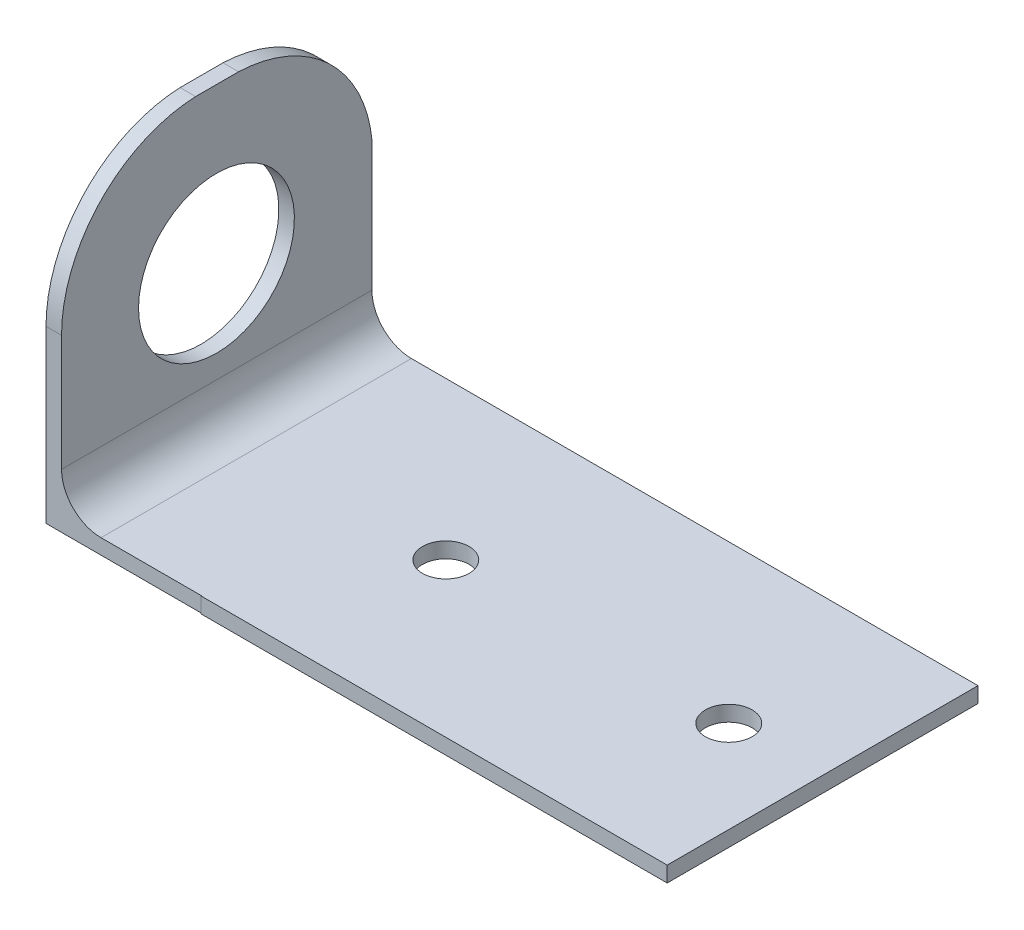
from build123d import *

# Parameters (mm, degrees)
EXTRUDE1_DEPTH     = 20
FILLET1_R          = 2.54
SKETCH8_R          = 5.014710823
CUT_EXTRUDE2_DEPTH = 10
CUT_EXTRUDE5_DEPTH = 10
CUT_EXTRUDE6_DEPTH = 10
CUT_EXTRUDE7_DEPTH = 30


with BuildPart() as part:
    # Sketch1 → Extrude1 (new body)
    with BuildSketch(Plane.XY):
        Polygon((1, 20), (1, 1), (40, 1), (40, 0), (0, 0), (0, 20), align=None)
    extrude(amount=EXTRUDE1_DEPTH)

    # Fillet1
    fillet1_edges = [part.edges().sort_by_distance(p)[0] for p in [
        (1, 1, 10),
    ]]
    fillet(fillet1_edges, radius=FILLET1_R)

    # Sketch8 → Cut-Extrude2 (cut)
    with BuildSketch(Plane.ZY):
        with Locations((10.002916517, 10.036253446)):
            Circle(SKETCH8_R)
    extrude(amount=-CUT_EXTRUDE2_DEPTH, mode=Mode.SUBTRACT)

    # Sketch9 → Cut-Extrude5 (cut)
    with BuildSketch(Plane.ZY):
        with BuildLine():
            Line((20, 20), (11.343762255, 20))
            ThreePointArc((11.343762255, 20), (17.466219012, 17.238892052), (19.972229781, 11.007671958))
            Line((19.972229781, 11.007671958), (19.972229781, 0.025510204))
            Line((19.972229781, 0.025510204), (0, 0.025510204))
            Line((0, 0.025510204), (0, 0))
            Line((0, 0), (20, 0))
            Line((20, 0), (20, 12.992821057))
            Line((20, 12.992821057), (20, 20))
        make_face()
        with BuildLine():
            ThreePointArc((0, 11.932412977), (2.787525204, 17.564709397), (8.580833361, 20))
            Line((8.580833361, 20), (0, 20))
            Line((0, 20), (0, 11.932412977))
        make_face()
    extrude(amount=-CUT_EXTRUDE5_DEPTH, mode=Mode.SUBTRACT)

    # Sketch10 → Cut-Extrude6 (cut)
    with BuildSketch(Plane(origin=(0, 1, 0), x_dir=(1, 0, 0), z_dir=(0, 1, 0))):
        with BuildLine():
            ThreePointArc((17.371397646, -10.116419243), (14.371398672, -10.114665052), (17.371393543, -10.119927624))
            ThreePointArc((17.371393543, -10.119927624), (17.37139662, -10.118173435), (17.371397646, -10.116419243))
        make_face()
    extrude(amount=-CUT_EXTRUDE6_DEPTH, mode=Mode.SUBTRACT)

    # Sketch11 → Cut-Extrude7 (cut)
    with BuildSketch(Plane(origin=(0, 1, 0), x_dir=(1, 0, 0), z_dir=(0, 1, 0))):
        with BuildLine():
            ThreePointArc((32.579372789, -10.112355136), (34.077335228, -11.616417867), (35.579367283, -10.116419243))
            ThreePointArc((35.579367283, -10.116419243), (34.081399338, -8.61642062), (32.579372789, -10.112355136))
        make_face()
    extrude(amount=-CUT_EXTRUDE7_DEPTH, mode=Mode.SUBTRACT)


solid = part.part
